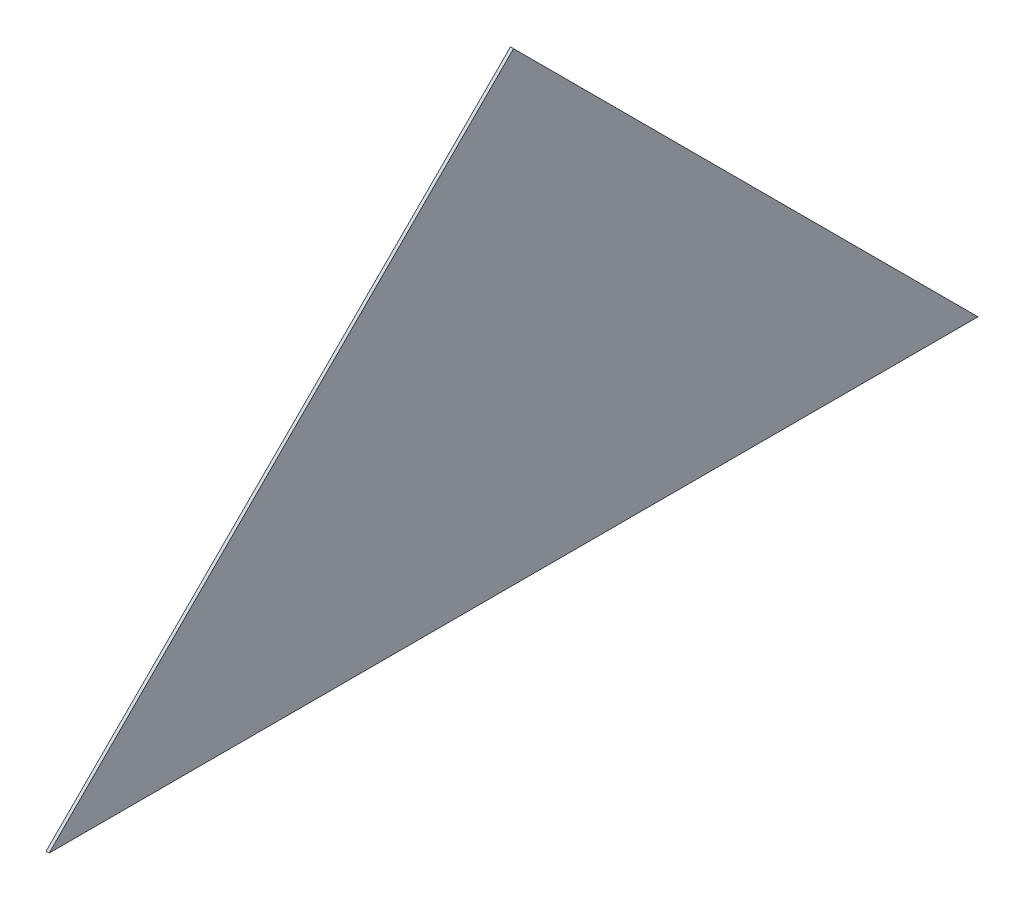
from build123d import *

# Parameters (mm, degrees)
EXTRUDE_1_DEPTH = 10


with BuildPart() as part:
    # 草图1 → 凸台-拉伸1 (new body)
    with BuildSketch(Plane(origin=(0, 0, 0), x_dir=(0, 0, -1), z_dir=(1, 0, 0))):
        Polygon((0, 0), (3000, 0), (1500.00004998, 1500), align=None)
    extrude(amount=EXTRUDE_1_DEPTH)


solid = part.part
